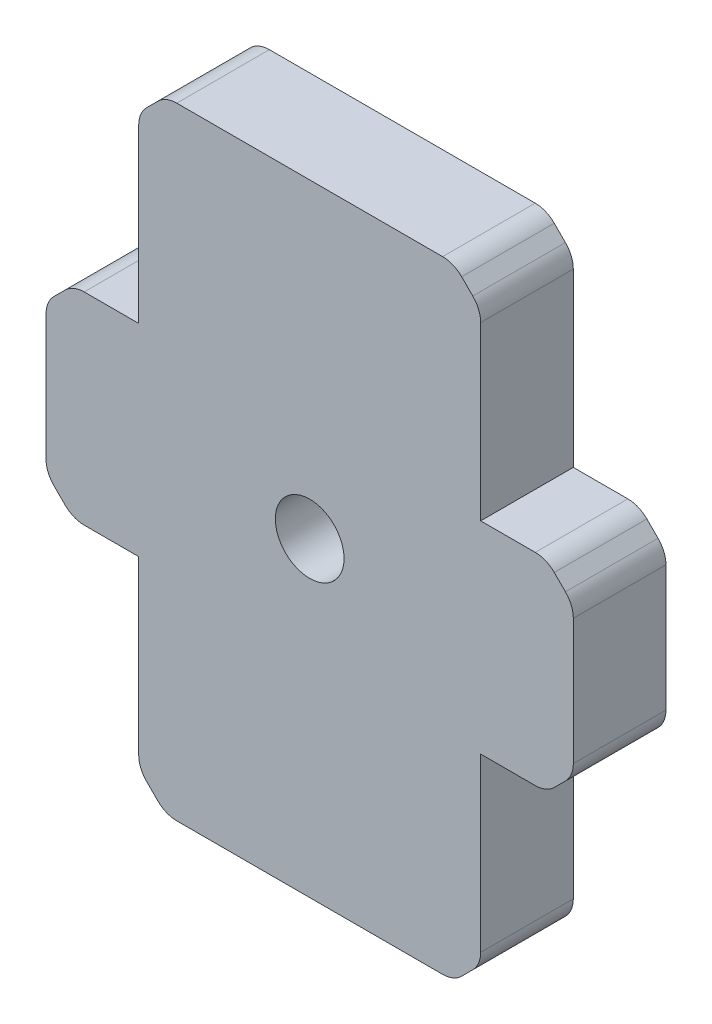
from build123d import *

# Parameters (mm, degrees)
SKETCH1_W           = 25.4
SKETCH1_H           = 46.164
BOSS_EXTRUDE1_DEPTH = 6.88
SKETCH2_W           = 13.76
SKETCH2_H           = 15
BOSS_EXTRUDE2_DEPTH = 6.88
SKETCH3_R           = 2.55
CUT_EXTRUDE1_DEPTH  = 7.88
CHAMFER1_SIZE       = 2
FILLET1_R           = 2


with BuildPart() as part:
    # Sketch1 → Boss-Extrude1 (new body)
    with BuildSketch(Plane.XY):
        Rectangle(SKETCH1_W, SKETCH1_H)
    extrude(amount=-BOSS_EXTRUDE1_DEPTH)

    # Sketch2 → Boss-Extrude2 (add)
    with BuildSketch(Plane.XY):
        with Locations((-12.7, 0)):
            Rectangle(SKETCH2_W, SKETCH2_H)
    boss_extrude2 = extrude(amount=-BOSS_EXTRUDE2_DEPTH)

    # Mirror2: Boss-Extrude2 across plane
    add(boss_extrude2.mirror(Plane(origin=(0, 0, 0), x_dir=(0, 0, 1), z_dir=(1, 0, 0))))

    # Sketch3 → Cut-Extrude1 (cut, through all)
    with BuildSketch(Plane.XY):
        Circle(SKETCH3_R)
    extrude(amount=-CUT_EXTRUDE1_DEPTH, mode=Mode.SUBTRACT)

    # Chamfer1
    chamfer1_edges = [part.edges().sort_by_distance(p)[0] for p in [
        (-19.58, -7.5, -3.44),
        (-19.58, 7.5, -3.44),
        (19.58, 7.5, -3.44),
        (19.58, -7.5, -3.44),
        (-12.7, 23.082, -3.44),
        (12.7, 23.082, -3.44),
        (12.7, -23.082, -3.44),
        (-12.7, -23.082, -3.44),
    ]]
    chamfer(chamfer1_edges, length=CHAMFER1_SIZE)

    # Fillet1
    fillet1_edges = [part.edges().sort_by_distance(p)[0] for p in [
        (10.7, 23.082, -3.44),
        (-10.7, 23.082, -3.44),
        (-12.7, 21.082, -3.44),
        (-17.58, 7.5, -3.44),
        (-19.58, -5.5, -3.44),
        (-19.58, 5.5, -3.44),
        (-17.58, -7.5, -3.44),
        (-12.7, -21.082, -3.44),
        (10.7, -23.082, -3.44),
        (-10.7, -23.082, -3.44),
        (12.7, -21.082, -3.44),
        (17.58, -7.5, -3.44),
        (19.58, 5.5, -3.44),
        (19.58, -5.5, -3.44),
        (12.7, 21.082, -3.44),
        (17.58, 7.5, -3.44),
    ]]
    fillet(fillet1_edges, radius=FILLET1_R)


solid = part.part
